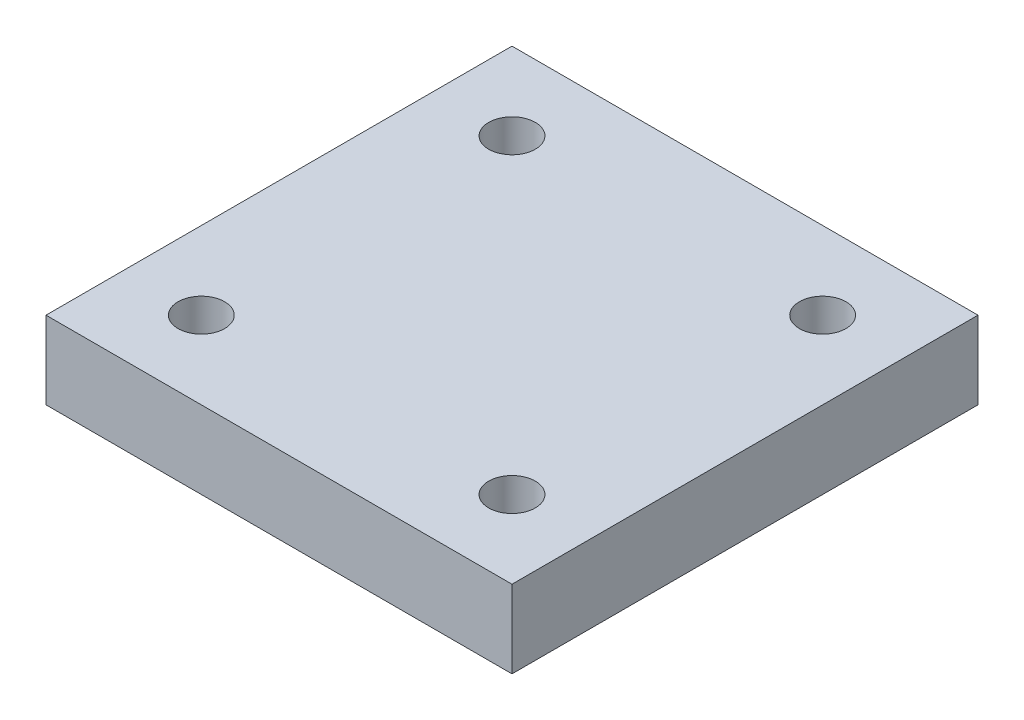
from build123d import *

# Parameters (mm, degrees)
SKETCH_1_W      = 30
SKETCH_1_H      = 30
SKETCH_1_R      = 1.5
EXTRUDE_1_DEPTH = 5


with BuildPart() as part:
    # 草图1 → 凸台-拉伸1 (new body)
    with BuildSketch(Plane(origin=(0, 0, 0), x_dir=(1, 0, 0), z_dir=(0, 1, 0))):
        Rectangle(SKETCH_1_W, SKETCH_1_H)
        with Locations((-10, 10)):
            Circle(SKETCH_1_R, mode=Mode.SUBTRACT)
        with Locations((10, 10)):
            Circle(SKETCH_1_R, mode=Mode.SUBTRACT)
        with Locations((10, -10)):
            Circle(SKETCH_1_R, mode=Mode.SUBTRACT)
        with Locations((-10, -10)):
            Circle(SKETCH_1_R, mode=Mode.SUBTRACT)
    extrude(amount=EXTRUDE_1_DEPTH)


solid = part.part
